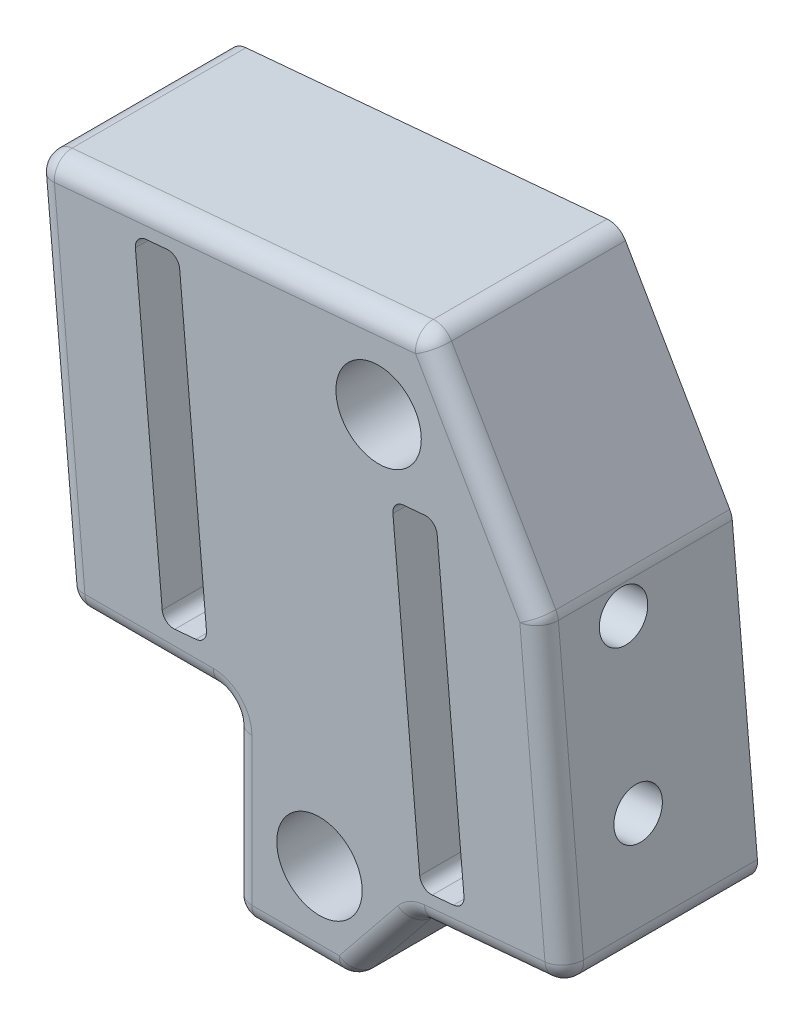
from build123d import *

# Parameters (mm, degrees)
BOSS_EXTRUDE1_DEPTH                      = 12.7
FILLET1_R                                = 1.27
CUT_EXTRUDE1_DEPTH                       = 13.7
FILLET2_R                                = 0.762
F_1_8_0_1250_DOWEL_HOLE1_D               = 3.175
F_1_8_0_1250_DOWEL_HOLE1_DEPTH           = 15.875
F_1_8_0_1250_DOWEL_HOLE1_TIP             = 0.953866233
F_1_8_0_1250_DOWEL_HOLE1_ON_FACE_2_D     = 3.175
F_1_8_0_1250_DOWEL_HOLE1_ON_FACE_2_DEPTH = 15.875
F_1_8_0_1250_DOWEL_HOLE1_ON_FACE_2_TIP   = 0.953866233
F_1_8_0_1250_DOWEL_HOLE1_ON_FACE_3_D     = 3.175
F_1_8_0_1250_DOWEL_HOLE1_ON_FACE_3_DEPTH = 15.875
F_1_8_0_1250_DOWEL_HOLE1_ON_FACE_3_TIP   = 0.953866233
F_1_8_0_1250_DOWEL_HOLE1_ON_FACE_4_D     = 3.175
F_1_8_0_1250_DOWEL_HOLE1_ON_FACE_4_DEPTH = 15.875
F_1_8_0_1250_DOWEL_HOLE1_ON_FACE_4_TIP   = 0.953866233
F_8_CLEARANCE_HOLE1_D                    = 4.4958
F_8_CLEARANCE_HOLE1_DEPTH                = 16.002
F_8_CLEARANCE_HOLE1_TIP                  = 1.350674586
F_2_0_221_DIAMETER_HOLE1_D               = 5.6134
F_2_0_221_DIAMETER_HOLE1_DEPTH           = 4.699
F_2_0_221_DIAMETER_HOLE1_TIP             = 1.686435499


with BuildPart() as part:
    # Sketch1 → Boss-Extrude1 (new body)
    with BuildSketch(Plane.XY):
        Polygon((19.247501297, -20.554356895), (17.457749907, -0.510490359), (10.059696167, 12.303314596), (-15.751947283, 9.998548464), (-13.531962325, -14.863609733), (-2.667, -14.863609733), (-2.667, -27.080616861), (4.953, -27.080616861), (9.525, -21.422495793), align=None)
    extrude(amount=BOSS_EXTRUDE1_DEPTH)

    # Fillet1
    fillet1_edges = [part.edges().sort_by_distance(p)[0] for p in [
        (1.143, -27.080616861, 12.7),
        (-2.667, -20.972113297, 12.7),
        (19.247501297, -20.554356895, 6.35),
        (17.457749907, -0.510490359, 6.35),
        (10.059696167, 12.303314596, 6.35),
        (-15.751947283, 9.998548464, 6.35),
        (-13.531962325, -14.863609733, 6.35),
        (-2.667, -14.863609733, 6.35),
        (-2.667, -27.080616861, 6.35),
        (4.953, -27.080616861, 6.35),
        (9.525, -21.422495793, 6.35),
        (-8.099481163, -14.863609733, 12.7),
        (-14.641954804, -2.432530634, 12.7),
        (-2.846125558, 11.15093153, 12.7),
        (13.758723037, 5.896412118, 12.7),
        (18.352625602, -10.532423627, 12.7),
        (14.386250649, -20.988426344, 12.7),
        (7.239, -24.251556327, 12.7),
    ]]
    fillet(fillet1_edges, radius=FILLET1_R)

    # Sketch2 → Cut-Extrude1 (cut, through all)
    with BuildSketch(Plane.XY.offset(12.7)):
        Polygon((-9.119892735, 8.550651548), (-6.210468147, 8.810439084), (-4.312889622, -12.441010084), (-7.22231421, -12.70079762), align=None)
        Polygon((7.808443636, 1.885201654), (10.717868225, 2.14498919), (12.61544675, -19.106459978), (9.706022161, -19.366247515), align=None)
    extrude(amount=-CUT_EXTRUDE1_DEPTH, mode=Mode.SUBTRACT)

    # Fillet2
    fillet2_edges = [part.edges().sort_by_distance(p)[0] for p in [
        (9.706022161, -19.366247515, 6.35),
        (7.808443636, 1.885201654, 6.35),
        (10.717868225, 2.14498919, 6.35),
        (12.61544675, -19.106459978, 6.35),
        (-7.22231421, -12.70079762, 6.35),
        (-9.119892735, 8.550651548, 6.35),
        (-6.210468147, 8.810439084, 6.35),
        (-4.312889622, -12.441010084, 6.35),
    ]]
    fillet(fillet2_edges, radius=FILLET2_R)

    # 1/8 (0.1250) Dowel Hole1
    with Locations(Plane(origin=(17.637948084, -2.528574118, 7.3025), x_dir=(-0.088937876, 0.996037175, 0), z_dir=(0.996037175, 0.088937876, 0))):
        with Locations((0, 0)):
            Hole(F_1_8_0_1250_DOWEL_HOLE1_D / 2, depth=F_1_8_0_1250_DOWEL_HOLE1_DEPTH)
            with Locations((0, 0, -(F_1_8_0_1250_DOWEL_HOLE1_DEPTH + F_1_8_0_1250_DOWEL_HOLE1_TIP / 2))):  # 118° drill point
                Cone(0, F_1_8_0_1250_DOWEL_HOLE1_D / 2, F_1_8_0_1250_DOWEL_HOLE1_TIP, mode=Mode.SUBTRACT)

    # 1/8 (0.1250) Dowel Hole1 on face 2
    with Locations(Plane(origin=(18.598032457, -13.280795423, 7.3025), x_dir=(-0.088938015, 0.996037163, 0), z_dir=(0.996037163, 0.088938015, 0))):
        with Locations((0, 0)):
            Hole(F_1_8_0_1250_DOWEL_HOLE1_ON_FACE_2_D / 2, depth=F_1_8_0_1250_DOWEL_HOLE1_ON_FACE_2_DEPTH)
            with Locations((0, 0, -(F_1_8_0_1250_DOWEL_HOLE1_ON_FACE_2_DEPTH + F_1_8_0_1250_DOWEL_HOLE1_ON_FACE_2_TIP / 2))):  # 118° drill point
                Cone(0, F_1_8_0_1250_DOWEL_HOLE1_ON_FACE_2_D / 2, F_1_8_0_1250_DOWEL_HOLE1_ON_FACE_2_TIP, mode=Mode.SUBTRACT)

    # 1/8 (0.1250) Dowel Hole1 on face 3
    with Locations(Plane(origin=(-15.102478442, 2.724986993, 7.3025), x_dir=(0.088938015, -0.996037163, 0), z_dir=(-0.996037163, -0.088938015, 0))):
        with Locations((0, 0)):
            Hole(F_1_8_0_1250_DOWEL_HOLE1_ON_FACE_3_D / 2, depth=F_1_8_0_1250_DOWEL_HOLE1_ON_FACE_3_DEPTH)
            with Locations((0, 0, -(F_1_8_0_1250_DOWEL_HOLE1_ON_FACE_3_DEPTH + F_1_8_0_1250_DOWEL_HOLE1_ON_FACE_3_TIP / 2))):  # 118° drill point
                Cone(0, F_1_8_0_1250_DOWEL_HOLE1_ON_FACE_3_D / 2, F_1_8_0_1250_DOWEL_HOLE1_ON_FACE_3_TIP, mode=Mode.SUBTRACT)

    # 1/8 (0.1250) Dowel Hole1 on face 4
    with Locations(Plane(origin=(-14.14239407, -8.027234313, 7.3025), x_dir=(0.088938015, -0.996037163, 0), z_dir=(-0.996037163, -0.088938015, 0))):
        with Locations((0, 0)):
            Hole(F_1_8_0_1250_DOWEL_HOLE1_ON_FACE_4_D / 2, depth=F_1_8_0_1250_DOWEL_HOLE1_ON_FACE_4_DEPTH)
            with Locations((0, 0, -(F_1_8_0_1250_DOWEL_HOLE1_ON_FACE_4_DEPTH + F_1_8_0_1250_DOWEL_HOLE1_ON_FACE_4_TIP / 2))):  # 118° drill point
                Cone(0, F_1_8_0_1250_DOWEL_HOLE1_ON_FACE_4_D / 2, F_1_8_0_1250_DOWEL_HOLE1_ON_FACE_4_TIP, mode=Mode.SUBTRACT)

    # #8 Clearance Hole1
    with Locations(Plane.XY.offset(12.7)):
        with Locations((6.934384891, 6.286512516), (3.048, -21.365616861)):
            Hole(F_8_CLEARANCE_HOLE1_D / 2, depth=F_8_CLEARANCE_HOLE1_DEPTH)
            with Locations((0, 0, -(F_8_CLEARANCE_HOLE1_DEPTH + F_8_CLEARANCE_HOLE1_TIP / 2))):  # 118° drill point
                Cone(0, F_8_CLEARANCE_HOLE1_D / 2, F_8_CLEARANCE_HOLE1_TIP, mode=Mode.SUBTRACT)

    # #2 (0.221) Diameter Hole1
    with Locations(Plane.XY.offset(12.7)):
        with Locations((6.934384891, 6.286512516), (3.048, -21.365616861)):
            Hole(F_2_0_221_DIAMETER_HOLE1_D / 2, depth=F_2_0_221_DIAMETER_HOLE1_DEPTH)
            with Locations((0, 0, -(F_2_0_221_DIAMETER_HOLE1_DEPTH + F_2_0_221_DIAMETER_HOLE1_TIP / 2))):  # 118° drill point
                Cone(0, F_2_0_221_DIAMETER_HOLE1_D / 2, F_2_0_221_DIAMETER_HOLE1_TIP, mode=Mode.SUBTRACT)


solid = part.part
